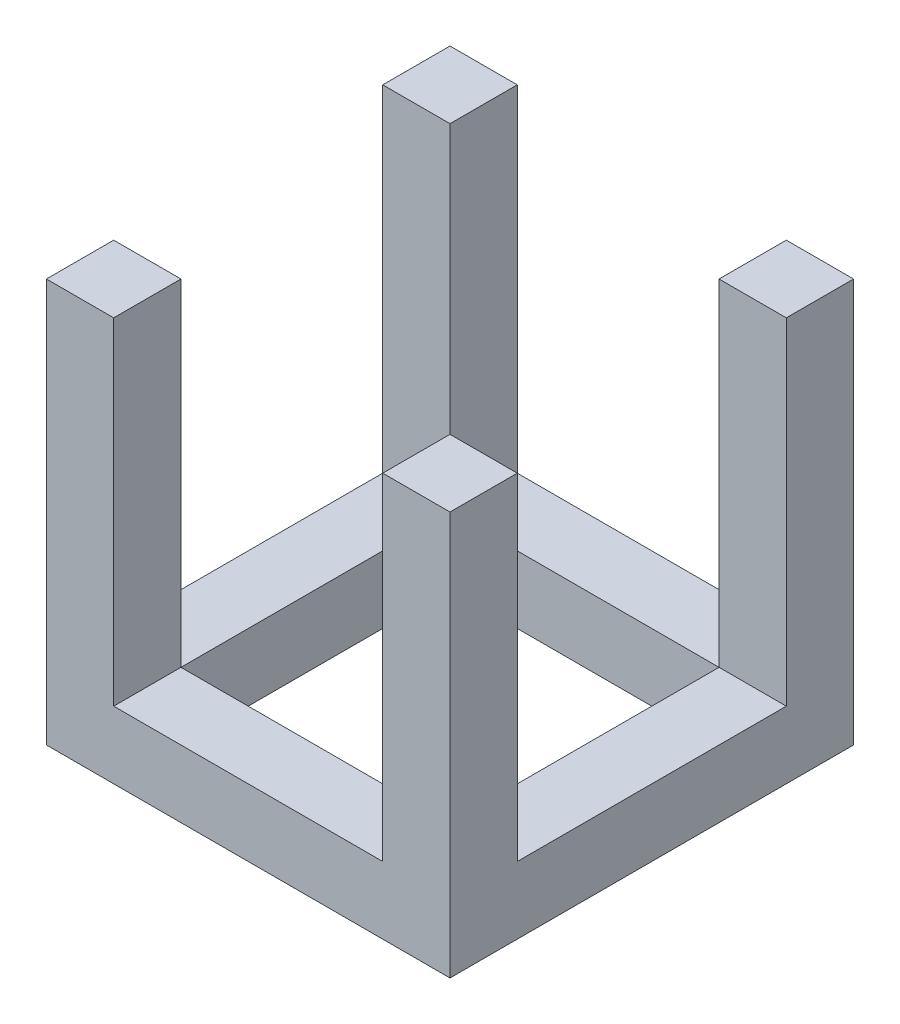
from build123d import *

# Parameters (mm, degrees)
ESQUISSE1_W             = 30
ESQUISSE1_H             = 30
ESQUISSE1_W_2           = 20
ESQUISSE1_H_2           = 20
BOSS_EXTRU_1_DEPTH      = 30
ESQUISSE3_W             = 20
ESQUISSE3_H             = 25
ENL_V_MAT_EXTRU_1_DEPTH = 31
ESQUISSE4_W             = 20
ESQUISSE4_H             = 25
ENL_V_MAT_EXTRU_2_DEPTH = 31


with BuildPart() as part:
    # Esquisse1 → Boss.-Extru.1 (new body)
    with BuildSketch(Plane(origin=(0, 0, 0), x_dir=(1, 0, 0), z_dir=(0, 1, 0))):
        Rectangle(ESQUISSE1_W, ESQUISSE1_H)
        Rectangle(ESQUISSE1_W_2, ESQUISSE1_H_2, mode=Mode.SUBTRACT)
    extrude(amount=BOSS_EXTRU_1_DEPTH)

    # Esquisse3 → Enlèv. mat.-Extru.1 (cut, through all)
    with BuildSketch(Plane.XY.offset(15)):
        with Locations((0, 17.5)):
            Rectangle(ESQUISSE3_W, ESQUISSE3_H)
    extrude(amount=-ENL_V_MAT_EXTRU_1_DEPTH, mode=Mode.SUBTRACT)

    # Esquisse4 → Enlèv. mat.-Extru.2 (cut, through all)
    with BuildSketch(Plane.ZY.offset(15)):
        with Locations((0, 17.5)):
            Rectangle(ESQUISSE4_W, ESQUISSE4_H)
    extrude(amount=-ENL_V_MAT_EXTRU_2_DEPTH, mode=Mode.SUBTRACT)


solid = part.part
